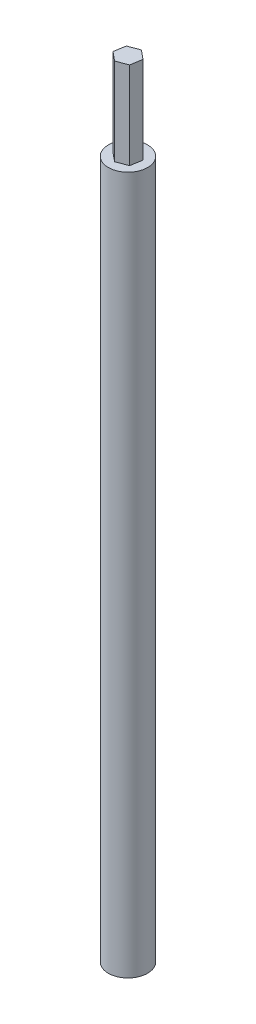
from build123d import *

# Parameters (mm, degrees)
SKETCH1_R           = 4.5
SKETCH1_R_2         = 2.314285714
BOSS_EXTRUDE1_DEPTH = 160
SKETCH1_3_R         = 2.314285714
CUT_EXTRUDE1_DEPTH  = 5
BOSS_EXTRUDE2_DEPTH = 20


with BuildPart() as part:
    # Sketch1 → Boss-Extrude1 (new body)
    with BuildSketch(Plane(origin=(0, 0, 0), x_dir=(1, 0, 0), z_dir=(0, 1, 0))):
        with Locations((-16.157558946, 16.157558946)):
            Circle(SKETCH1_R)
        with Locations((-16.157558946, 16.157558946)):
            Circle(SKETCH1_R_2, mode=Mode.SUBTRACT)
    extrude(amount=BOSS_EXTRUDE1_DEPTH)

    # Sketch1_3 → Cut-Extrude1 (cut)
    with BuildSketch(Plane(origin=(0, 0, 0), x_dir=(1, 0, 0), z_dir=(0, 1, 0))):
        Polygon((-14.281170571, 12.907558946), (-12.404782196, 16.157558946), (-14.281170571, 19.407558946), (-18.033947321, 19.407558946), (-19.910335696, 16.157558946), (-18.033947321, 12.907558946), align=None)
        with Locations((-16.157558946, 16.157558946)):
            Circle(SKETCH1_3_R, mode=Mode.SUBTRACT)
    extrude(amount=CUT_EXTRUDE1_DEPTH, mode=Mode.SUBTRACT)

    # Sketch2 → Boss-Extrude2 (add)
    with BuildSketch(Plane(origin=(0, 160, 0), x_dir=(1, 0, 0), z_dir=(0, 1, 0))):
        Polygon((-14.092245618, 14.462942882), (-13.657321721, 17.098864722), (-15.722635049, 18.793480786), (-18.222872273, 17.852175009), (-18.65779617, 15.216253169), (-16.592482843, 13.521637106), align=None)
    extrude(amount=BOSS_EXTRUDE2_DEPTH)


solid = part.part
